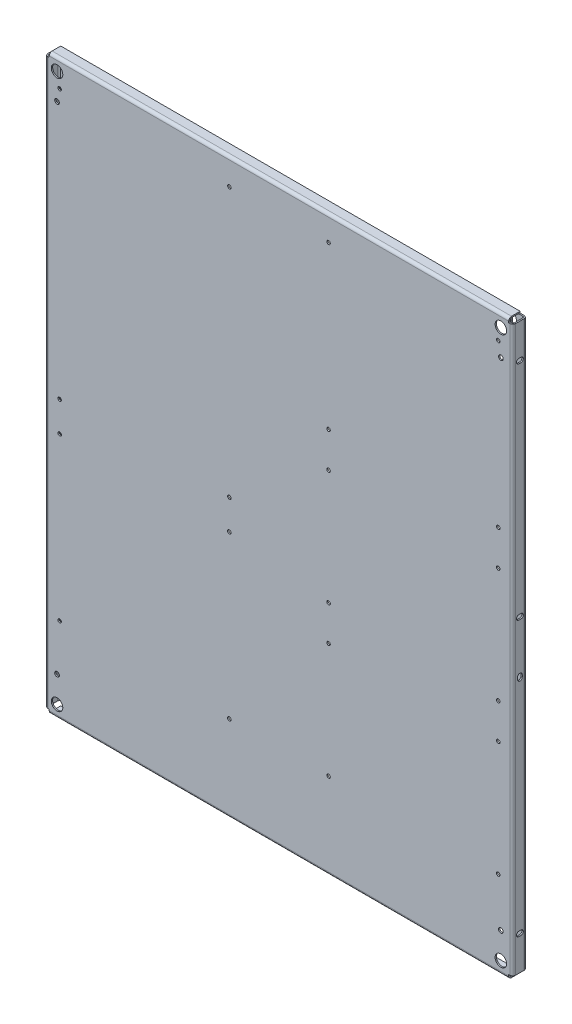
from build123d import *

# Parameters (mm, degrees)
ESQUISSE1_W                                   = 896
ESQUISSE1_H                                   = 1080.9248
BOSS_EXTRU_1_DEPTH                            = 27
ENL_V_MAT_EXTRU_1_DEPTH                       = 1081.9248
ESQUISSE3_W                                   = 879.9248
ESQUISSE3_H                                   = 2.5
BOSS_EXTRU_2_DEPTH                            = 8.0376
ESQUISSE4_W                                   = 879.9248
ESQUISSE4_H                                   = 2.5
BOSS_EXTRU_3_DEPTH                            = 19.5
ESQUISSE5_W                                   = 879.9248
ESQUISSE5_H                                   = 2.5
BOSS_EXTRU_4_DEPTH                            = 8.0376
ESQUISSE6_W                                   = 879.9248
ESQUISSE6_H                                   = 2.5
BOSS_EXTRU_5_DEPTH                            = 19.5
ENL_V_MAT_EXTRU_2_REACH                       = 29
ENL_V_MAT_EXTRU_3_DEPTH                       = 3.5
ENL_V_MAT_EXTRU_4_DEPTH                       = 3.5
ENL_V_MAT_EXTRU_5_DEPTH                       = 3.5
ENL_V_MAT_EXTRU_6_DEPTH                       = 3.5
ENL_V_MAT_EXTRU_7_DEPTH                       = 3.5
ENL_V_MAT_EXTRU_8_DEPTH                       = 3.5
ENL_V_MAT_EXTRU_9_REACH                       = 898
ENL_V_MAT_EXTRU_10_REACH                      = 898
ENL_V_MAT_EXTRU_11_REACH                      = 898
ENL_V_MAT_EXTRU_12_REACH                      = 898
ENL_V_MAT_EXTRU_13_REACH                      = 29
DIAM_TRE_DU_PER_AGE_9_0_9_1_D                 = 9
DIAM_TRE_DU_PER_AGE_9_0_9_1_DEPTH             = 2.5
DIAM_TRE_DU_PER_AGE_22_0_22_1_D               = 22
DIAM_TRE_DU_PER_AGE_22_0_22_1_DEPTH           = 2.5
CONG_1_R                                      = 3
CONG_2_R                                      = 5.5
TROU_POUR_TARAUDAGE_POUR_TROU_TARAUD_M8_D     = 6.8
TROU_POUR_TARAUDAGE_POUR_TROU_TARAUD_M8_DEPTH = 40
TROU_POUR_TARAUDAGE_POUR_TROU_TARAUD_M8_TIP   = 2.042926105
TROU_POUR_TARAUDAGE_POUR_TROU_TARAUD_2_D      = 6.8
TROU_POUR_TARAUDAGE_POUR_TROU_TARAUD_2_DEPTH  = 40
TROU_POUR_TARAUDAGE_POUR_TROU_TARAUD_2_TIP    = 2.042926105


with BuildPart() as part:
    # Esquisse1 → Boss.-Extru.1 (new body)
    with BuildSketch(Plane.XY):
        Rectangle(ESQUISSE1_W, ESQUISSE1_H)
    extrude(amount=-BOSS_EXTRU_1_DEPTH)

    # Esquisse2 → Enlèv. mat.-Extru.1 (cut, through all)
    with BuildSketch(Plane(origin=(0, 540.4624, 0), x_dir=(-1, 0, 0), z_dir=(0, 1, 0))):
        Polygon((415, -27), (415, -24.5), (445.5, -24.5), (445.5, -2.5), (-445.5, -2.5), (-445.5, -24.5), (-415, -24.5), (-415, -27), align=None)
    extrude(amount=-ENL_V_MAT_EXTRU_1_DEPTH, mode=Mode.SUBTRACT)

    # Esquisse3 → Boss.-Extru.2 (add)
    with BuildSketch(Plane.XZ.offset(540.4624)):
        with Locations((0, -1.25)):
            Rectangle(ESQUISSE3_W, ESQUISSE3_H)
    extrude(amount=BOSS_EXTRU_2_DEPTH)

    # Esquisse4 → Boss.-Extru.3 (add)
    with BuildSketch(Plane(origin=(0, 0, -2.5), x_dir=(-1, 0, 0), z_dir=(0, 0, -1))):
        with Locations((0, -547.25)):
            Rectangle(ESQUISSE4_W, ESQUISSE4_H)
    extrude(amount=BOSS_EXTRU_3_DEPTH)

    # Esquisse5 → Boss.-Extru.4 (add)
    with BuildSketch(Plane(origin=(0, 540.4624, 0), x_dir=(-1, 0, 0), z_dir=(0, 1, 0))):
        with Locations((0, -1.25)):
            Rectangle(ESQUISSE5_W, ESQUISSE5_H)
    extrude(amount=BOSS_EXTRU_4_DEPTH)

    # Esquisse6 → Boss.-Extru.5 (add)
    with BuildSketch(Plane(origin=(0, 0, -2.5), x_dir=(-1, 0, 0), z_dir=(0, 0, -1))):
        with Locations((0, 547.25)):
            Rectangle(ESQUISSE6_W, ESQUISSE6_H)
    extrude(amount=BOSS_EXTRU_5_DEPTH)

    # Esquisse7 → Enlèv. mat.-Extru.2 (cut, up to next)
    with BuildSketch(Plane(origin=(0, 0, -27), x_dir=(-1, 0, 0), z_dir=(0, 0, -1)), mode=Mode.PRIVATE) as enl_v_mat_extru_2_sk1:
        with BuildLine():
            Line((-430, -521), (-430, -529))
            ThreePointArc((-430, -529), (-425, -534), (-420, -529))
            Line((-420, -529), (-420, -521))
            ThreePointArc((-420, -521), (-425, -516), (-430, -521))
        make_face()
    enl_v_mat_extru_2_tool1 = extrude(enl_v_mat_extru_2_sk1.sketch, amount=-ENL_V_MAT_EXTRU_2_REACH, mode=Mode.PRIVATE) & part.part
    add(enl_v_mat_extru_2_tool1.solids().sort_by_distance((425, -525, -27))[0], mode=Mode.SUBTRACT)

    # Esquisse8 → Enlèv. mat.-Extru.3 (cut, through all)
    with BuildSketch(Plane.ZY.offset(-445.5)):
        with BuildLine():
            Line((-9, -52), (-9, -48))
            ThreePointArc((-9, -48), (-13.5, -43.5), (-18, -48))
            Line((-18, -48), (-18, -52))
            ThreePointArc((-18, -52), (-13.5, -56.5), (-9, -52))
        make_face()
    extrude(amount=-ENL_V_MAT_EXTRU_3_DEPTH, mode=Mode.SUBTRACT)

    # Esquisse9 → Enlèv. mat.-Extru.4 (cut, through all)
    with BuildSketch(Plane.ZY.offset(-445.5)):
        with BuildLine():
            Line((-11.5, -470.5), (-15.5, -470.5))
            ThreePointArc((-15.5, -470.5), (-20, -475), (-15.5, -479.5))
            Line((-15.5, -479.5), (-11.5, -479.5))
            ThreePointArc((-11.5, -479.5), (-7, -475), (-11.5, -470.5))
        make_face()
    extrude(amount=-ENL_V_MAT_EXTRU_4_DEPTH, mode=Mode.SUBTRACT)

    # Esquisse10 → Enlèv. mat.-Extru.5 (cut, through all)
    with BuildSketch(Plane.ZY.offset(-445.5)):
        with BuildLine():
            Line((-11.5, 479.5), (-15.5, 479.5))
            ThreePointArc((-15.5, 479.5), (-20, 475), (-15.5, 470.5))
            Line((-15.5, 470.5), (-11.5, 470.5))
            ThreePointArc((-11.5, 470.5), (-7, 475), (-11.5, 479.5))
        make_face()
    extrude(amount=-ENL_V_MAT_EXTRU_5_DEPTH, mode=Mode.SUBTRACT)

    # Esquisse11 → Enlèv. mat.-Extru.6 (cut, through all)
    with BuildSketch(Plane.ZY.offset(-445.5)):
        with BuildLine():
            Line((-11.5, 54.5), (-15.5, 54.5))
            ThreePointArc((-15.5, 54.5), (-20, 50), (-15.5, 45.5))
            Line((-15.5, 45.5), (-11.5, 45.5))
            ThreePointArc((-11.5, 45.5), (-7, 50), (-11.5, 54.5))
        make_face()
    extrude(amount=-ENL_V_MAT_EXTRU_6_DEPTH, mode=Mode.SUBTRACT)

    # Esquisse12 → Enlèv. mat.-Extru.7 (cut, through all)
    with BuildSketch(Plane.XY.offset(-24.5)):
        with BuildLine():
            Line((430, 521), (430, 529))
            ThreePointArc((430, 529), (425, 534), (420, 529))
            Line((420, 529), (420, 521))
            ThreePointArc((420, 521), (425, 516), (430, 521))
        make_face()
    extrude(amount=-ENL_V_MAT_EXTRU_7_DEPTH, mode=Mode.SUBTRACT)

    # Esquisse13 → Enlèv. mat.-Extru.8 (cut, through all)
    with BuildSketch(Plane.XY.offset(-24.5)):
        with BuildLine():
            Line((-430, -521), (-430, -529))
            ThreePointArc((-430, -529), (-425, -534), (-420, -529))
            Line((-420, -529), (-420, -521))
            ThreePointArc((-420, -521), (-425, -516), (-430, -521))
        make_face()
    extrude(amount=-ENL_V_MAT_EXTRU_8_DEPTH, mode=Mode.SUBTRACT)

    # Esquisse14 → Enlèv. mat.-Extru.9 (cut, up to next)
    with BuildSketch(Plane.ZY.offset(448), mode=Mode.PRIVATE) as enl_v_mat_extru_9_sk1:
        with BuildLine():
            Line((-11.5, -45.5), (-15.5, -45.5))
            ThreePointArc((-15.5, -45.5), (-20, -50), (-15.5, -54.5))
            Line((-15.5, -54.5), (-11.5, -54.5))
            ThreePointArc((-11.5, -54.5), (-7, -50), (-11.5, -45.5))
        make_face()
    enl_v_mat_extru_9_tool1 = extrude(enl_v_mat_extru_9_sk1.sketch, amount=-ENL_V_MAT_EXTRU_9_REACH, mode=Mode.PRIVATE) & part.part
    add(enl_v_mat_extru_9_tool1.solids().sort_by_distance((-448, -50, -13.5))[0], mode=Mode.SUBTRACT)

    # Esquisse15 → Enlèv. mat.-Extru.10 (cut, up to next)
    with BuildSketch(Plane.ZY.offset(448), mode=Mode.PRIVATE) as enl_v_mat_extru_10_sk1:
        with BuildLine():
            Line((-9, -477), (-9, -473))
            ThreePointArc((-9, -473), (-13.5, -468.5), (-18, -473))
            Line((-18, -473), (-18, -477))
            ThreePointArc((-18, -477), (-13.5, -481.5), (-9, -477))
        make_face()
    enl_v_mat_extru_10_tool1 = extrude(enl_v_mat_extru_10_sk1.sketch, amount=-ENL_V_MAT_EXTRU_10_REACH, mode=Mode.PRIVATE) & part.part
    add(enl_v_mat_extru_10_tool1.solids().sort_by_distance((-448, -475, -13.5))[0], mode=Mode.SUBTRACT)

    # Esquisse16 → Enlèv. mat.-Extru.11 (cut, up to next)
    with BuildSketch(Plane.ZY.offset(448), mode=Mode.PRIVATE) as enl_v_mat_extru_11_sk1:
        with BuildLine():
            Line((-9, 473), (-9, 477))
            ThreePointArc((-9, 477), (-13.5, 481.5), (-18, 477))
            Line((-18, 477), (-18, 473))
            ThreePointArc((-18, 473), (-13.5, 468.5), (-9, 473))
        make_face()
    enl_v_mat_extru_11_tool1 = extrude(enl_v_mat_extru_11_sk1.sketch, amount=-ENL_V_MAT_EXTRU_11_REACH, mode=Mode.PRIVATE) & part.part
    add(enl_v_mat_extru_11_tool1.solids().sort_by_distance((-448, 475, -13.5))[0], mode=Mode.SUBTRACT)

    # Esquisse17 → Enlèv. mat.-Extru.12 (cut, up to next)
    with BuildSketch(Plane.ZY.offset(448), mode=Mode.PRIVATE) as enl_v_mat_extru_12_sk1:
        with BuildLine():
            Line((-9, 48), (-9, 52))
            ThreePointArc((-9, 52), (-13.5, 56.5), (-18, 52))
            Line((-18, 52), (-18, 48))
            ThreePointArc((-18, 48), (-13.5, 43.5), (-9, 48))
        make_face()
    enl_v_mat_extru_12_tool1 = extrude(enl_v_mat_extru_12_sk1.sketch, amount=-ENL_V_MAT_EXTRU_12_REACH, mode=Mode.PRIVATE) & part.part
    add(enl_v_mat_extru_12_tool1.solids().sort_by_distance((-448, 50, -13.5))[0], mode=Mode.SUBTRACT)

    # Esquisse18 → Enlèv. mat.-Extru.13 (cut, up to next)
    with BuildSketch(Plane(origin=(0, 0, -27), x_dir=(-1, 0, 0), z_dir=(0, 0, -1)), mode=Mode.PRIVATE) as enl_v_mat_extru_13_sk1:
        with BuildLine():
            Line((430, 521), (430, 529))
            ThreePointArc((430, 529), (425, 534), (420, 529))
            Line((420, 529), (420, 521))
            ThreePointArc((420, 521), (425, 516), (430, 521))
        make_face()
    enl_v_mat_extru_13_tool1 = extrude(enl_v_mat_extru_13_sk1.sketch, amount=-ENL_V_MAT_EXTRU_13_REACH, mode=Mode.PRIVATE) & part.part
    add(enl_v_mat_extru_13_tool1.solids().sort_by_distance((-425, 525, -27))[0], mode=Mode.SUBTRACT)

    # Diamètre du perçage Ø9.0 (9)1
    with Locations(Plane(origin=(0, 0, -2.5), x_dir=(-1, 0, 0), z_dir=(0, 0, -1))):
        with Locations((425, -475), (425, 475), (-425, -475), (-425, 475)):
            Hole(DIAM_TRE_DU_PER_AGE_9_0_9_1_D / 2, depth=DIAM_TRE_DU_PER_AGE_9_0_9_1_DEPTH)

    # Diamètre du perçage Ø22.0 (22)1
    with Locations(Plane(origin=(0, 0, -2.5), x_dir=(-1, 0, 0), z_dir=(0, 0, -1))):
        with Locations((425, -525), (425, 525), (-425, -525), (-425, 525)):
            Hole(DIAM_TRE_DU_PER_AGE_22_0_22_1_D / 2, depth=DIAM_TRE_DU_PER_AGE_22_0_22_1_DEPTH)

    # Congé1
    cong_1_edges = [part.edges().sort_by_distance(p)[0] for p in [
        (445.5, 0, -24.5),
        (445.5, 0, -2.5),
        (-445.5, 0, -2.5),
        (-445.5, 0, -24.5),
        (0, -546, -2.5),
        (0, 546, -2.5),
    ]]
    fillet(cong_1_edges, radius=CONG_1_R)

    # Congé2
    cong_2_edges = [part.edges().sort_by_distance(p)[0] for p in [
        (448, 0, -27),
        (448, 0, 0),
        (0, -548.5, 0),
        (-448, 0, 0),
        (-448, 0, -27),
        (0, 548.5, 0),
    ]]
    fillet(cong_2_edges, radius=CONG_2_R)

    # Trou pour taraudage pour trou taraud_ M8
    with Locations(Plane.XY):
        with Locations((-420, 498.5)):
            Hole(TROU_POUR_TARAUDAGE_POUR_TROU_TARAUD_M8_D / 2, depth=TROU_POUR_TARAUDAGE_POUR_TROU_TARAUD_M8_DEPTH)
            with Locations((0, 0, -(TROU_POUR_TARAUDAGE_POUR_TROU_TARAUD_M8_DEPTH + TROU_POUR_TARAUDAGE_POUR_TROU_TARAUD_M8_TIP / 2))):  # 118° drill point
                Cone(0, TROU_POUR_TARAUDAGE_POUR_TROU_TARAUD_M8_D / 2, TROU_POUR_TARAUDAGE_POUR_TROU_TARAUD_M8_TIP, mode=Mode.SUBTRACT)

    # Trou pour taraudage pour trou taraud 2
    with Locations(Plane.XY):
        with Locations((-95, 498.5), (95, 501), (420, 501), (420, 191), (420, 123.5), (95, 191), (95, 123.5), (95, -96.5), (95, -164), (420, -96.5), (420, -164), (420, -384), (95, -384), (-95, -384), (-420, -384), (-420, -74), (-420, -16.5), (-95, -16.5), (-95, -74)):
            Hole(TROU_POUR_TARAUDAGE_POUR_TROU_TARAUD_2_D / 2, depth=TROU_POUR_TARAUDAGE_POUR_TROU_TARAUD_2_DEPTH)
            with Locations((0, 0, -(TROU_POUR_TARAUDAGE_POUR_TROU_TARAUD_2_DEPTH + TROU_POUR_TARAUDAGE_POUR_TROU_TARAUD_2_TIP / 2))):  # 118° drill point
                Cone(0, TROU_POUR_TARAUDAGE_POUR_TROU_TARAUD_2_D / 2, TROU_POUR_TARAUDAGE_POUR_TROU_TARAUD_2_TIP, mode=Mode.SUBTRACT)


solid = part.part
